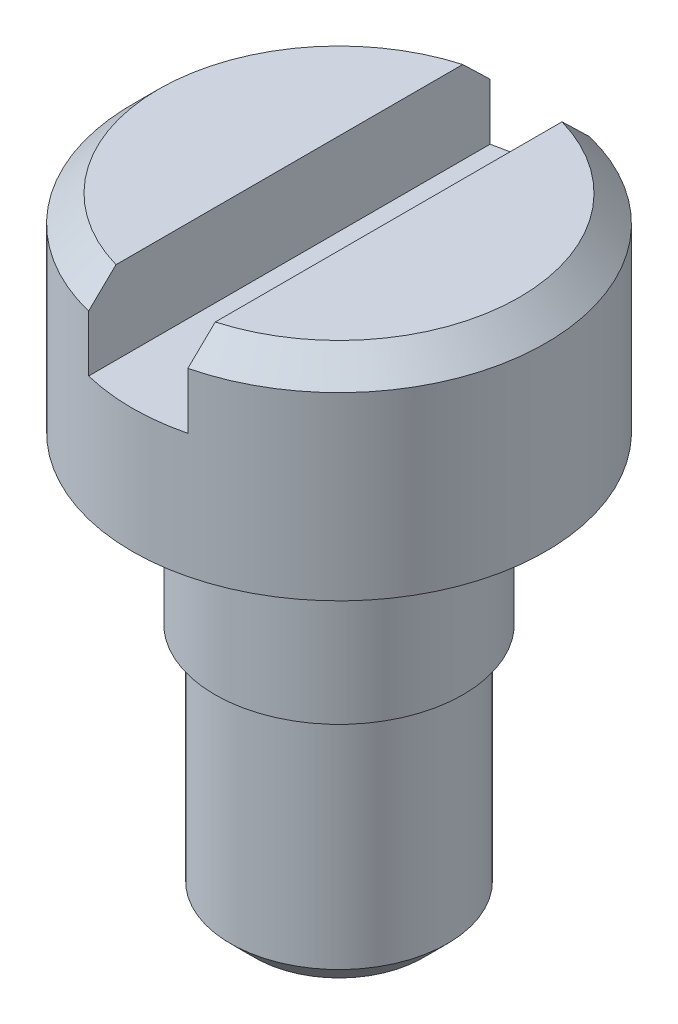
from build123d import *

# Parameters (mm, degrees)
SKETCH1_R          = 3.96875
EXTRUDE1_DEPTH     = 3.96875
SKETCH2_W          = 1.905
SKETCH2_H          = 7.9375
CUT_EXTRUDE1_DEPTH = 1.5875
SKETCH4_R          = 2.38125
EXTRUDE2_DEPTH     = 3.175
SKETCH5_R          = 2.0828
EXTRUDE3_DEPTH     = 4.7625
CHAMFER1_SIZE      = 0.508
CHAMFER2_SIZE      = 0.47625


with BuildPart() as part:
    # Sketch1 → Extrude1 (new body)
    with BuildSketch(Plane(origin=(0, 0, 0), x_dir=(1, 0, 0), z_dir=(0, 1, 0))):
        Circle(SKETCH1_R)
    extrude(amount=EXTRUDE1_DEPTH)

    # Sketch2 → Cut-Extrude1 (cut)
    with BuildSketch(Plane(origin=(0, 3.96875, 0), x_dir=(-1, 0, 0), z_dir=(0, 1, 0))):
        Rectangle(SKETCH2_W, SKETCH2_H)
    extrude(amount=-CUT_EXTRUDE1_DEPTH, mode=Mode.SUBTRACT)

    # Sketch4 → Extrude2 (add)
    with BuildSketch(Plane.XZ):
        Circle(SKETCH4_R)
    extrude(amount=EXTRUDE2_DEPTH)

    # Sketch5 → Extrude3 (add)
    with BuildSketch(Plane.XZ.offset(3.175)):
        Circle(SKETCH5_R)
    extrude(amount=EXTRUDE3_DEPTH)

    # Chamfer1
    chamfer1_edges = [part.edges().sort_by_distance(p)[0] for p in [
        (-3.96875, 3.96875, 0),
        (3.124996875, 3.96875, -2.446501807),
    ]]
    chamfer(chamfer1_edges, length=CHAMFER1_SIZE)

    # Chamfer2
    chamfer2_edges = [part.edges().sort_by_distance(p)[0] for p in [
        (-2.0828, -7.9375, 0),
    ]]
    chamfer(chamfer2_edges, length=CHAMFER2_SIZE)


solid = part.part
